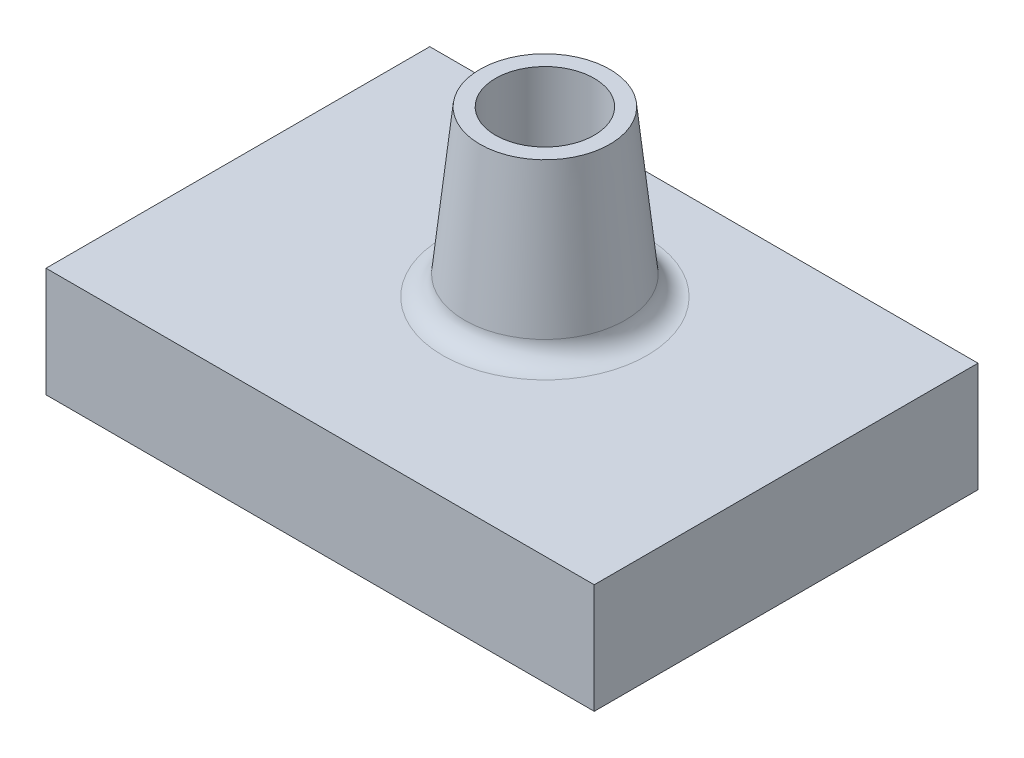
from build123d import *

# Parameters (mm, degrees)
SKETCH1_W           = 50
SKETCH1_H           = 35
BOSS_EXTRUDE1_DEPTH = 10
SKETCH2_R           = 7.5
BOSS_EXTRUDE2_DEPTH = 15
BOSS_EXTRUDE2_TAPER = 6
SKETCH3_R           = 4.5
CUT_EXTRUDE1_DEPTH  = 15
FILLET1_R           = 2


with BuildPart() as part:
    # Sketch1 → Boss-Extrude1 (new body)
    with BuildSketch(Plane(origin=(0, 0, 0), x_dir=(1, 0, 0), z_dir=(0, 1, 0))):
        Rectangle(SKETCH1_W, SKETCH1_H)
    extrude(amount=BOSS_EXTRUDE1_DEPTH)

    # Sketch2 → Boss-Extrude2 (add)
    with BuildSketch(Plane(origin=(0, 10, 0), x_dir=(1, 0, 0), z_dir=(0, 1, 0))):
        with Locations((0, 3)):
            Circle(SKETCH2_R)
    extrude(amount=BOSS_EXTRUDE2_DEPTH, taper=BOSS_EXTRUDE2_TAPER)

    # Sketch3 → Cut-Extrude1 (cut)
    with BuildSketch(Plane(origin=(0, 25, 0), x_dir=(1, 0, 0), z_dir=(0, 1, 0))):
        with Locations((0, 3)):
            Circle(SKETCH3_R)
    extrude(amount=-CUT_EXTRUDE1_DEPTH, mode=Mode.SUBTRACT)

    # Fillet1
    fillet1_edges = [part.edges().sort_by_distance(p)[0] for p in [
        (-7.5, 10, -3),
    ]]
    fillet(fillet1_edges, radius=FILLET1_R)


solid = part.part
